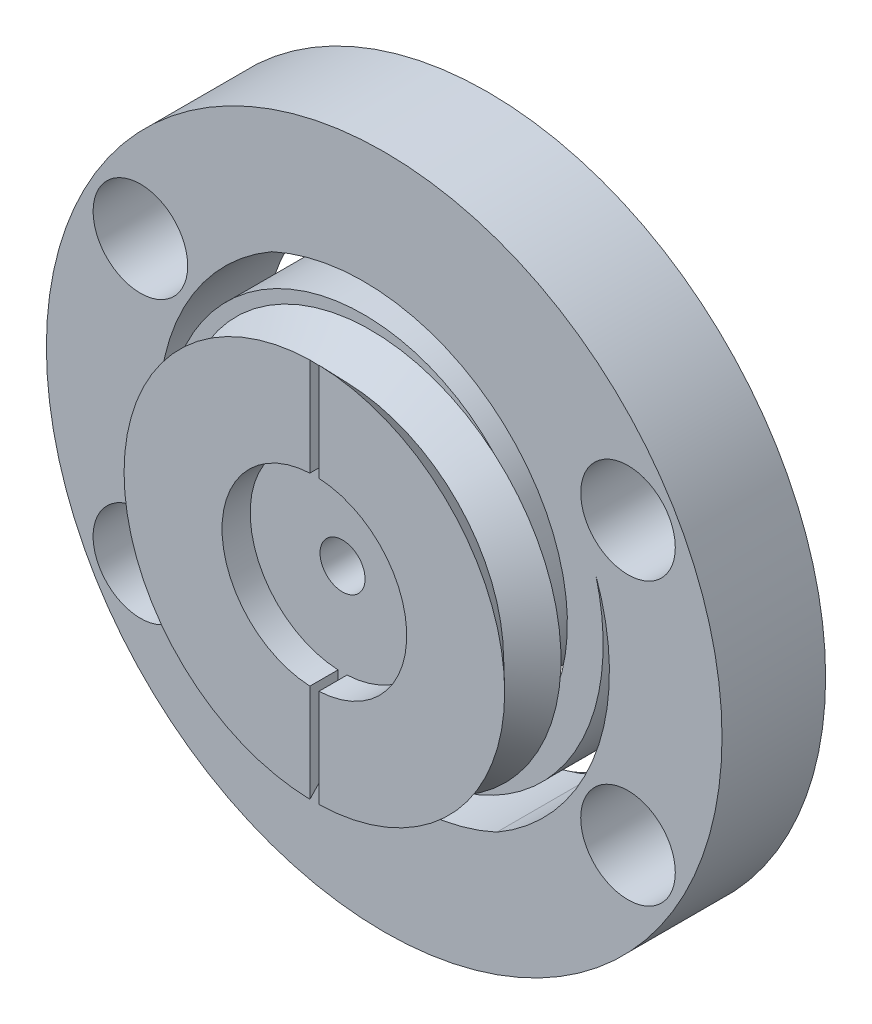
from build123d import *

# Parameters (mm, degrees)
SKETCH_2_R           = 15
SKETCH_2_R_2         = 10
EXTRUDE_2_DEPTH      = 4.6
SKETCH_23_R          = 2.1
CUT_EXTRUDE_8_DEPTH  = 3.1
SKETCH_24_R          = 1.2
CUT_EXTRUDE_9_DEPTH  = 2.5
EXTRUDE_3_DEPTH      = 4.4
SKETCH_19_R          = 3.975
EXTRUDE_6_DEPTH      = 3.4
SKETCH_9_R           = 3.1
CUT_EXTRUDE_1_DEPTH  = 3.1
SKETCH_10_R          = 4
EXTRUDE_4_DEPTH      = 0.6
SKETCH_11_R          = 8.45
EXTRUDE_5_DEPTH      = 2.5
SKETCH_25_R          = 1
CUT_EXTRUDE_10_DEPTH = 7
CUT_EXTRUDE_11_DEPTH = 1.25


with BuildPart() as part:
    # 스케치2 → 보스-돌출2 (new body)
    with BuildSketch(Plane.XY):
        Circle(SKETCH_2_R)
        Circle(SKETCH_2_R_2, mode=Mode.SUBTRACT)
    extrude(amount=EXTRUDE_2_DEPTH)

    # 스케치23 → 컷-돌출8 (cut)
    with BuildSketch(Plane.XY.offset(4.6)):
        with Locations((10.825317547, 6.25)):
            Circle(SKETCH_23_R)
        with Locations((-10.825317547, 6.25)):
            Circle(SKETCH_23_R)
        with Locations((10.825317547, -6.25)):
            Circle(SKETCH_23_R)
        with Locations((-10.825317547, -6.25)):
            Circle(SKETCH_23_R)
    extrude(amount=-CUT_EXTRUDE_8_DEPTH, mode=Mode.SUBTRACT)

    # 스케치24 → 컷-돌출9 (cut, through all)
    with BuildSketch(Plane.XY.offset(1.5)):
        with Locations((-10.825317547, 6.25)):
            Circle(SKETCH_24_R)
        with Locations((10.825317547, 6.25)):
            Circle(SKETCH_24_R)
        with Locations((10.825317547, -6.25)):
            Circle(SKETCH_24_R)
        with Locations((-10.825317547, -6.25)):
            Circle(SKETCH_24_R)
    extrude(amount=-CUT_EXTRUDE_9_DEPTH, mode=Mode.SUBTRACT)

    # 스케치8 → 보스-돌출3 (add)
    with BuildSketch(Plane.XY.offset(4.6)):
        with BuildLine():
            ThreePointArc((-2.125, 3.680607966), (-3.993693638, 1.453585609), (-3.993693638, -1.453585609))
            add(Edge.make_bspline(
                [(-9.396926208, -3.420201433), (-9.732062183, -2.149175506), (-9.806172611, -0.835010365), (-9.456725912, 1.676046677), (-9.033681598, 2.871966971), (-7.789656699, 4.972884513), (-6.969506065, 5.877213907), (-5.085556702, 7.278578571), (-4.022753032, 7.775339442), (-1.834341922, 8.316896689), (-0.709724019, 8.361833006), (1.425354593, 8.02880188), (2.434991624, 7.65134079), (4.194832357, 6.566362619), (4.944502403, 5.859612911), (6.091617732, 4.253128009), (6.488888652, 3.354278704), (6.901731194, 1.519508339), (6.917493401, 0.584437672), (6.600877847, -1.174662508), (6.268999982, -1.998016278), (5.34306854, -3.416780201), (4.749719757, -4.011790899), (3.420699316, -4.904656893), (2.685804375, -5.202437862), (1.204674755, -5.486565699), (0.459151326, -5.473153796), (-0.923970423, -5.172953815), (-1.561040931, -4.886659174), (-2.638728045, -4.11977446), (-3.079079395, -3.639826603), (-3.717696054, -2.588270623), (-3.915987072, -2.017330047), (-3.993693638, -1.453585609)],
                knots=[0, 0, 0, 0, 0.0625, 0.0625, 0.125, 0.125, 0.1875, 0.1875, 0.25, 0.25, 0.3125, 0.3125, 0.375, 0.375, 0.4375, 0.4375, 0.5, 0.5, 0.5625, 0.5625, 0.625, 0.625, 0.6875, 0.6875, 0.75, 0.75, 0.8125, 0.8125, 0.875, 0.875, 0.9375, 0.9375, 1, 1, 1, 1], degree=3))
            ThreePointArc((-9.396926208, -3.420201433), (-3.420201433, -9.396926208), (5, -8.660254038))
            add(Edge.make_bspline(
                [(5, -8.660254038), (3.806479564, -9.211009881), (2.525148685, -9.512196786), (-0.008440541, -9.604099447), (-1.259652992, -9.395151506), (-3.544675532, -8.534846644), (-4.577683795, -7.884191092), (-6.284902954, -6.272207574), (-6.958670832, -5.311811899), (-7.872014208, -3.250688101), (-8.111555691, -2.150958779), (-8.154336566, 0.009513438), (-7.957931589, 1.069357245), (-7.195029811, 2.990866525), (-6.629196056, 3.851873198), (-5.246311756, 5.260524443), (-4.430103363, 5.807843469), (-2.694896637, 6.533018535), (-1.776768874, 6.710914596), (0.010586336, 6.704573685), (0.879061498, 6.520711671), (2.437057517, 5.855212978), (3.126062601, 5.37420102), (4.236145931, 4.220415939), (4.657016106, 3.548394826), (5.194022862, 2.139105174), (5.310273501, 1.402578969), (5.254810803, -0.011659233), (5.083491754, -0.688765751), (4.515396145, -1.883248509), (4.119205984, -2.400252004), (3.194520122, -3.21176742), (2.666686289, -3.506188743), (2.125, -3.680607966)],
                knots=[0, 0, 0, 0, 0.0625, 0.0625, 0.125, 0.125, 0.1875, 0.1875, 0.25, 0.25, 0.3125, 0.3125, 0.375, 0.375, 0.4375, 0.4375, 0.5, 0.5, 0.5625, 0.5625, 0.625, 0.625, 0.6875, 0.6875, 0.75, 0.75, 0.8125, 0.8125, 0.875, 0.875, 0.9375, 0.9375, 1, 1, 1, 1], degree=3))
            ThreePointArc((2.125, -3.680607966), (3.993693638, -1.453585609), (3.993693638, 1.453585609))
            add(Edge.make_bspline(
                [(9.396926208, 3.420201433), (9.732062183, 2.149175506), (9.806172611, 0.835010365), (9.456725912, -1.676046677), (9.033681598, -2.871966971), (7.789656699, -4.972884513), (6.969506065, -5.877213907), (5.085556702, -7.278578571), (4.022753032, -7.775339442), (1.834341922, -8.316896689), (0.709724019, -8.361833006), (-1.425354593, -8.02880188), (-2.434991624, -7.65134079), (-4.194832357, -6.566362619), (-4.944502403, -5.859612911), (-6.091617732, -4.253128009), (-6.488888652, -3.354278704), (-6.901731194, -1.519508339), (-6.917493401, -0.584437672), (-6.600877847, 1.174662508), (-6.268999982, 1.998016278), (-5.34306854, 3.416780201), (-4.749719757, 4.011790899), (-3.420699316, 4.904656893), (-2.685804375, 5.202437862), (-1.204674755, 5.486565699), (-0.459151326, 5.473153796), (0.923970423, 5.172953815), (1.561040931, 4.886659174), (2.638728045, 4.11977446), (3.079079395, 3.639826603), (3.717696054, 2.588270623), (3.915987072, 2.017330047), (3.993693638, 1.453585609)],
                knots=[0, 0, 0, 0, 0.0625, 0.0625, 0.125, 0.125, 0.1875, 0.1875, 0.25, 0.25, 0.3125, 0.3125, 0.375, 0.375, 0.4375, 0.4375, 0.5, 0.5, 0.5625, 0.5625, 0.625, 0.625, 0.6875, 0.6875, 0.75, 0.75, 0.8125, 0.8125, 0.875, 0.875, 0.9375, 0.9375, 1, 1, 1, 1], degree=3))
            ThreePointArc((9.396926208, 3.420201433), (3.420201433, 9.396926208), (-5, 8.660254038))
            add(Edge.make_bspline(
                [(-5, 8.660254038), (-3.806479564, 9.211009881), (-2.525148685, 9.512196786), (0.008440541, 9.604099447), (1.259652992, 9.395151506), (3.544675532, 8.534846644), (4.577683795, 7.884191092), (6.284902954, 6.272207574), (6.958670832, 5.311811899), (7.872014208, 3.250688101), (8.111555691, 2.150958779), (8.154336566, -0.009513438), (7.957931589, -1.069357245), (7.195029811, -2.990866525), (6.629196056, -3.851873198), (5.246311756, -5.260524443), (4.430103363, -5.807843469), (2.694896637, -6.533018535), (1.776768874, -6.710914596), (-0.010586336, -6.704573685), (-0.879061498, -6.520711671), (-2.437057517, -5.855212978), (-3.126062601, -5.37420102), (-4.236145931, -4.220415939), (-4.657016106, -3.548394826), (-5.194022862, -2.139105174), (-5.310273501, -1.402578969), (-5.254810803, 0.011659233), (-5.083491754, 0.688765751), (-4.515396145, 1.883248509), (-4.119205984, 2.400252004), (-3.194520122, 3.21176742), (-2.666686289, 3.506188743), (-2.125, 3.680607966)],
                knots=[0, 0, 0, 0, 0.0625, 0.0625, 0.125, 0.125, 0.1875, 0.1875, 0.25, 0.25, 0.3125, 0.3125, 0.375, 0.375, 0.4375, 0.4375, 0.5, 0.5, 0.5625, 0.5625, 0.625, 0.625, 0.6875, 0.6875, 0.75, 0.75, 0.8125, 0.8125, 0.875, 0.875, 0.9375, 0.9375, 1, 1, 1, 1], degree=3))
        make_face()
    extrude(amount=-EXTRUDE_3_DEPTH)

    # 스케치19 → 보스-돌출6 (add)
    with BuildSketch(Plane(origin=(0, 0, 0.2), x_dir=(-1, 0, 0), z_dir=(0, 0, -1))):
        Circle(SKETCH_19_R)
    extrude(amount=EXTRUDE_6_DEPTH)

    # 스케치9 → 컷-돌출1 (cut)
    with BuildSketch(Plane(origin=(0, 0, -3.2), x_dir=(-1, 0, 0), z_dir=(0, 0, -1))):
        Circle(SKETCH_9_R)
    extrude(amount=-CUT_EXTRUDE_1_DEPTH, mode=Mode.SUBTRACT)

    # 스케치10 → 보스-돌출4 (add)
    with BuildSketch(Plane.XY.offset(4.6)):
        Circle(SKETCH_10_R)
    extrude(amount=EXTRUDE_4_DEPTH)

    # 스케치11 → 보스-돌출5 (add)
    with BuildSketch(Plane.XY.offset(5.2)):
        Circle(SKETCH_11_R)
    extrude(amount=EXTRUDE_5_DEPTH)

    # 스케치12 → 컷-회전1 (revolve, cut)
    with BuildSketch(Plane(origin=(0, 0, 0), x_dir=(0, 0, -1), z_dir=(1, 0, 0))):
        Polygon((-7.7, 8.45), (-5.2, 8.45), (-6.45, 7.15), align=None)
    revolve(axis=Axis((0, 0, 0), (0, 0, 1)), mode=Mode.SUBTRACT)

    # 스케치25 → 컷-돌출10 (cut)
    with BuildSketch(Plane.XY.offset(7.7)):
        Circle(SKETCH_25_R)
    extrude(amount=-CUT_EXTRUDE_10_DEPTH, mode=Mode.SUBTRACT)

    # 스케치26 → 컷-돌출11 (cut)
    with BuildSketch(Plane.XY.offset(7.7)):
        with BuildLine():
            Line((-0.2, 4.095119046), (-0.2, 9))
            Line((-0.2, 9), (0.2, 9))
            Line((0.2, 9), (0.2, 4.095119046))
            ThreePointArc((0.2, 4.095119046), (4.1, 0), (0.2, -4.095119046))
            Line((0.2, -4.095119046), (0.2, -9))
            Line((0.2, -9), (-0.2, -9))
            Line((-0.2, -9), (-0.2, -4.095119046))
            ThreePointArc((-0.2, -4.095119046), (-4.1, 0), (-0.2, 4.095119046))
        make_face()
    extrude(amount=-CUT_EXTRUDE_11_DEPTH, mode=Mode.SUBTRACT)


solid = part.part
